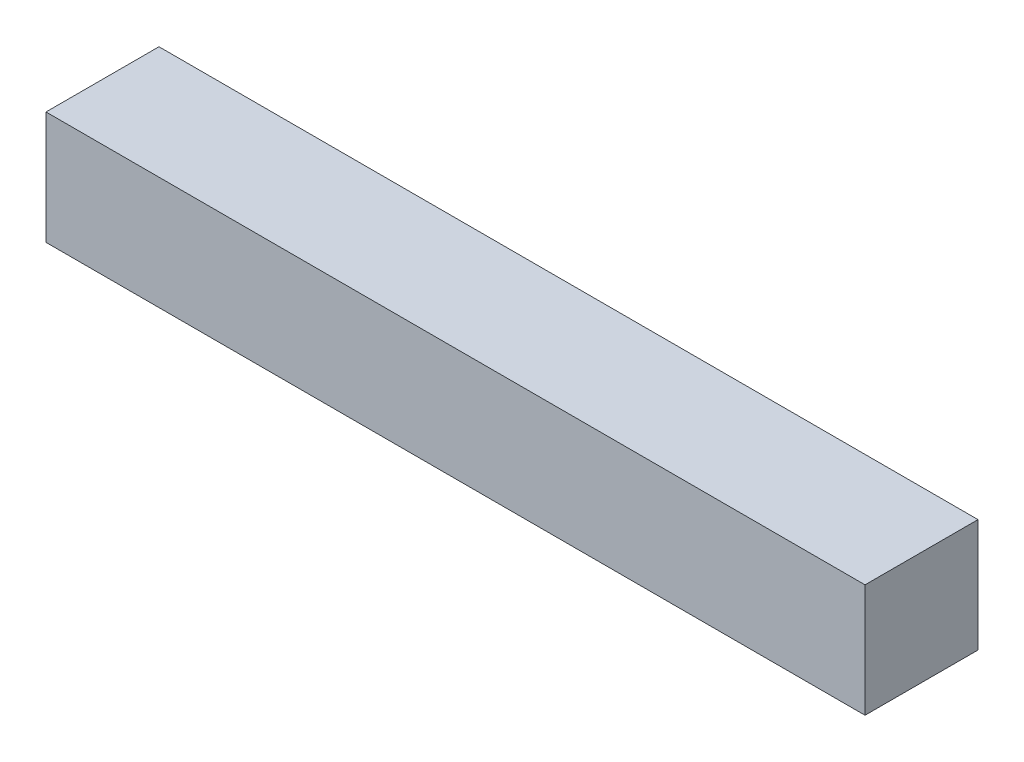
from build123d import *

# Parameters (mm, degrees)
SKETCH1_W           = 14.5
SKETCH1_H           = 2
BOSS_EXTRUDE1_DEPTH = 2


with BuildPart() as part:
    # Sketch1 → Boss-Extrude1 (new body)
    with BuildSketch(Plane.XY):
        with Locations((7.25, 1)):
            Rectangle(SKETCH1_W, SKETCH1_H)
    extrude(amount=BOSS_EXTRUDE1_DEPTH)


solid = part.part
